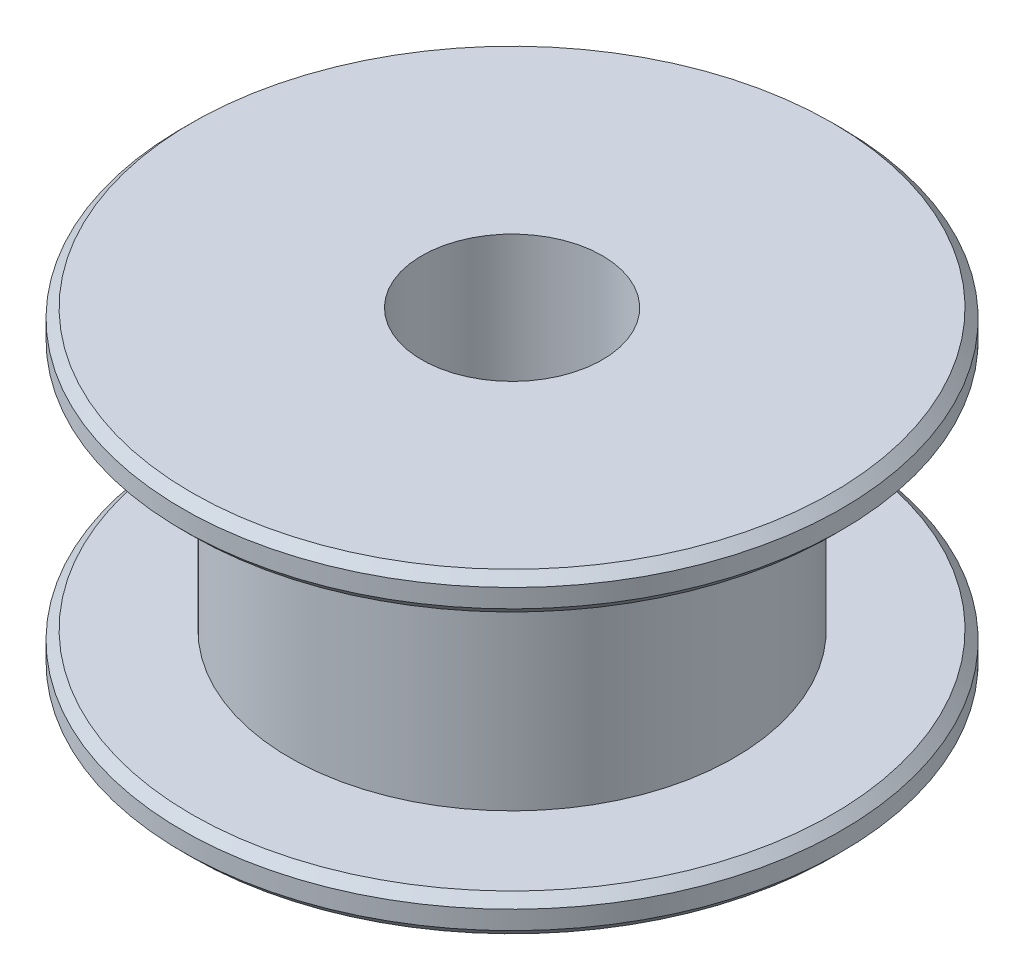
from build123d import *


with BuildPart() as part:
    # Sketch1 → Revolve1 (revolve)
    with BuildSketch(Plane.XY):
        Polygon((2.4765, 8.6614), (2.4765, 0), (8.7884, 0), (9.0424, 0.254), (9.0424, 0.762), (8.7884, 1.016), (6.096, 1.016), (6.096, 7.6454), (8.7884, 7.6454), (9.0424, 7.8994), (9.0424, 8.4074), (8.7884, 8.6614), align=None)
    revolve(axis=Axis((0, 8.6614, 0), (0, -1, 0)))


solid = part.part
